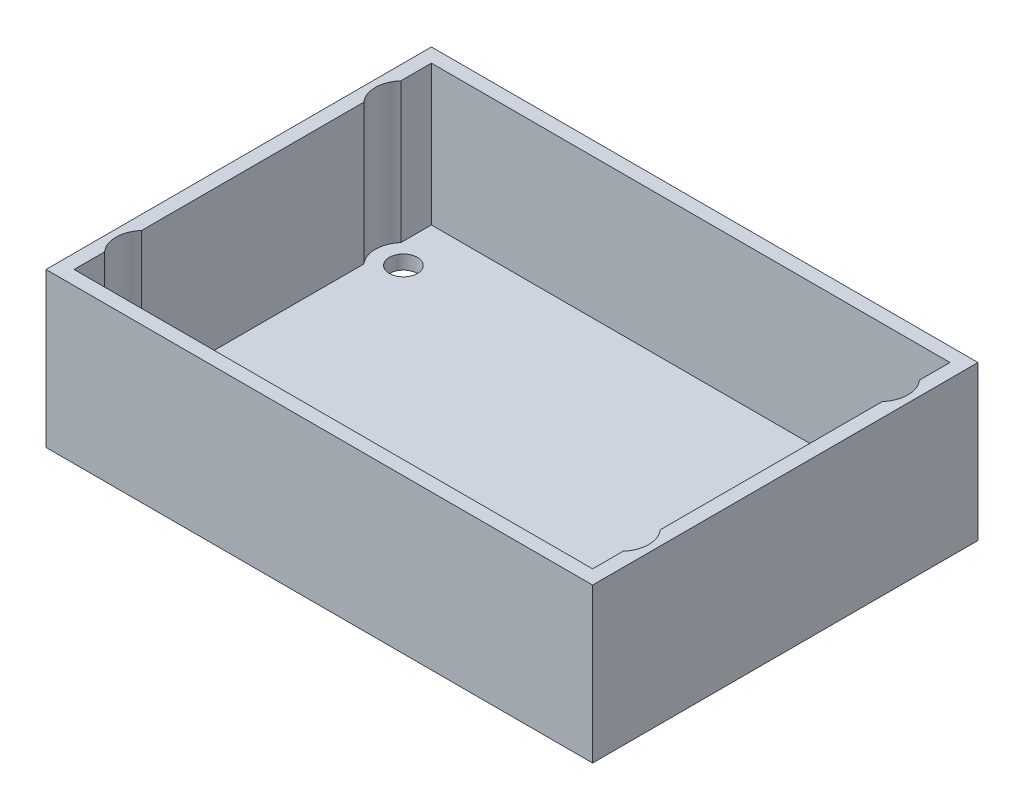
from build123d import *

# Parameters (mm, degrees)
SKETCH_1_W          = 78
SKETCH_1_H          = 55
EXTRUDE_1_DEPTH     = 22
SKETCH_2_W          = 74
SKETCH_2_H          = 51
CUT_EXTRUDE_1_DEPTH = 20
SKETCH_4_R          = 4
CUT_EXTRUDE_2_DEPTH = 20
SKETCH_5_R          = 2
CUT_EXTRUDE_4_DEPTH = 23


with BuildPart() as part:
    # 草图1 → 凸台-拉伸1 (new body)
    with BuildSketch(Plane(origin=(0, 0, 0), x_dir=(1, 0, 0), z_dir=(0, 1, 0))):
        with Locations((39, 27.5)):
            Rectangle(SKETCH_1_W, SKETCH_1_H)
    extrude(amount=EXTRUDE_1_DEPTH)

    # 草图2 → 切除-拉伸1 (cut)
    with BuildSketch(Plane(origin=(0, 22, 0), x_dir=(1, 0, 0), z_dir=(0, 1, 0))):
        with Locations((39, 27.5)):
            Rectangle(SKETCH_2_W, SKETCH_2_H)
    extrude(amount=-CUT_EXTRUDE_1_DEPTH, mode=Mode.SUBTRACT)

    # 草图4 → 切除-拉伸2 (cut)
    with BuildSketch(Plane(origin=(0, 22, 0), x_dir=(1, 0, 0), z_dir=(0, 1, 0))):
        with Locations((5, 9)):
            Circle(SKETCH_4_R)
        with Locations((5, 46)):
            Circle(SKETCH_4_R)
        with Locations((73, 46)):
            Circle(SKETCH_4_R)
        with Locations((73, 9)):
            Circle(SKETCH_4_R)
    extrude(amount=-CUT_EXTRUDE_2_DEPTH, mode=Mode.SUBTRACT)

    # 草图5 → 切除-拉伸4 (cut, through all)
    with BuildSketch(Plane(origin=(0, 22, 0), x_dir=(1, 0, 0), z_dir=(0, 1, 0))):
        with Locations((5, 9)):
            Circle(SKETCH_5_R)
        with Locations((5, 46)):
            Circle(SKETCH_5_R)
        with Locations((73, 46)):
            Circle(SKETCH_5_R)
        with Locations((73, 9)):
            Circle(SKETCH_5_R)
    extrude(amount=-CUT_EXTRUDE_4_DEPTH, mode=Mode.SUBTRACT)


solid = part.part
